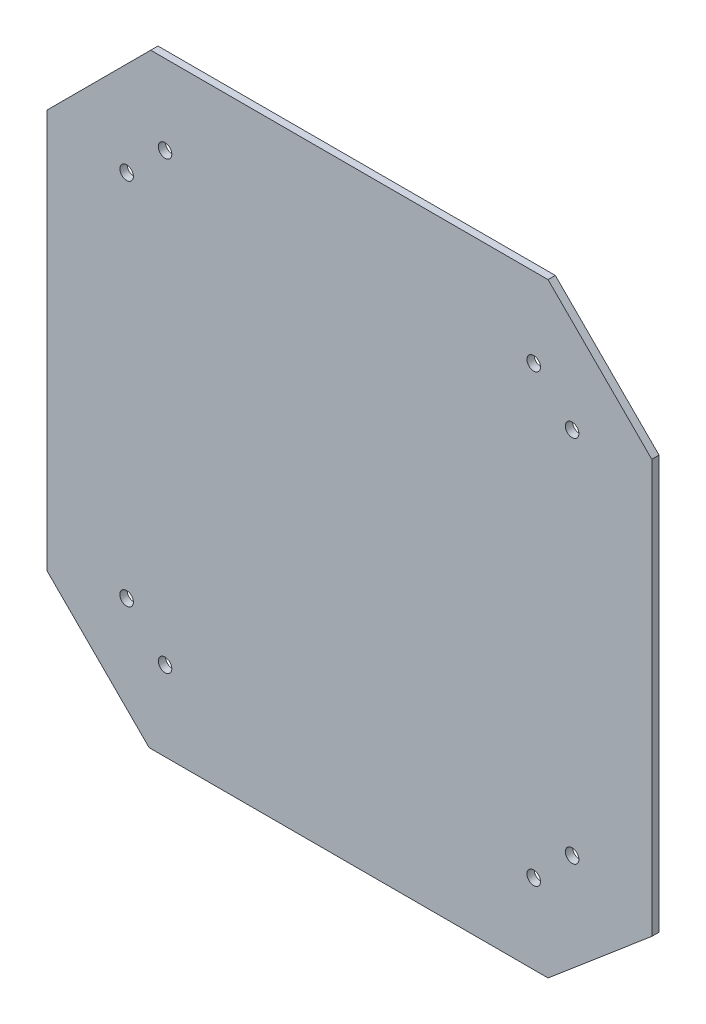
from build123d import *

# Parameters (mm, degrees)
SKETCH1_W      = 125
SKETCH1_H      = 125
SKETCH1_R      = 1.4
EXTRUDE1_DEPTH = 1.5
EXTRUDE2_DEPTH = 10


with BuildPart() as part:
    # Sketch1 → Extrude1 (new body)
    with BuildSketch(Plane.XY):
        Rectangle(SKETCH1_W, SKETCH1_H)
        with Locations((46.0375, 38.1)):
            Circle(SKETCH1_R, mode=Mode.SUBTRACT)
        with Locations((38.1, 46.0375)):
            Circle(SKETCH1_R, mode=Mode.SUBTRACT)
        with Locations((-38.1, 46.0375)):
            Circle(SKETCH1_R, mode=Mode.SUBTRACT)
        with Locations((-46.0375, 38.1)):
            Circle(SKETCH1_R, mode=Mode.SUBTRACT)
        with Locations((-46.0375, -38.1)):
            Circle(SKETCH1_R, mode=Mode.SUBTRACT)
        with Locations((-38.1, -46.0375)):
            Circle(SKETCH1_R, mode=Mode.SUBTRACT)
        with Locations((38.1, -46.0375)):
            Circle(SKETCH1_R, mode=Mode.SUBTRACT)
        with Locations((46.0375, -38.1)):
            Circle(SKETCH1_R, mode=Mode.SUBTRACT)
    extrude(amount=EXTRUDE1_DEPTH)

    # Sketch2 → Extrude2 (cut)
    with BuildSketch(Plane.XY.offset(1.5)):
        Polygon((41.063122539, -62.5), (62.5, -44.338577872), (62.5, -62.5), align=None)
        Polygon((41.063122539, 62.5), (62.5, 41.063122539), (62.5, 62.5), align=None)
        Polygon((-41.384179801, -62.5), (-62.5, -41.384179801), (-62.5, -62.5), align=None)
        Polygon((-62.5, 41.063122539), (-41.063122539, 62.5), (-62.5, 62.5), align=None)
    extrude(amount=-EXTRUDE2_DEPTH, mode=Mode.SUBTRACT)


solid = part.part
